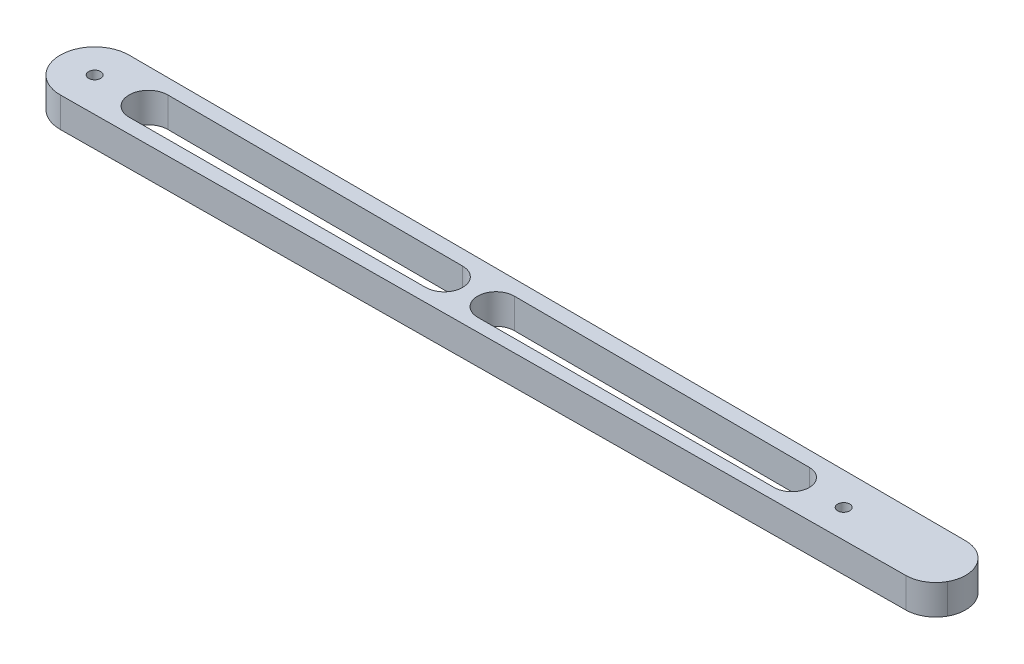
from build123d import *

# Parameters (mm, degrees)
SKETCH1_R           = 2
BOSS_EXTRUDE1_DEPTH = 10
CUT_EXTRUDE1_DEPTH  = 11


with BuildPart() as part:
    # Sketch1 → Boss-Extrude1 (new body)
    with BuildSketch(Plane(origin=(0, 0, 0), x_dir=(1, 0, 0), z_dir=(0, 1, 0))):
        with BuildLine():
            Line((0.090909042, -11.49964067), (280.070567987, -9.286294776))
            ThreePointArc((280.070567987, -9.286294776), (289.991484188, 0.738871766), (280.019610714, 10.7133533))
            Line((280.019610714, 10.7133533), (0.032308177, 11.499954617))
            ThreePointArc((0.032308177, 11.499954617), (-11.499962672, -0.029300853), (0.090909042, -11.49964067))
        make_face()
        with Locations((250, 0)):
            Circle(SKETCH1_R, mode=Mode.SUBTRACT)
        Circle(SKETCH1_R, mode=Mode.SUBTRACT)
    extrude(amount=BOSS_EXTRUDE1_DEPTH)

    # Sketch2 → Cut-Extrude1 (cut, through all)
    with BuildSketch(Plane(origin=(0, 10, 0), x_dir=(1, 0, 0), z_dir=(0, 1, 0))):
        with BuildLine():
            Line((17.967691823, 6.449546898), (116.670959066, 6.17224818))
            ThreePointArc((116.670959066, 6.17224818), (122.825891181, 0), (116.670959066, -6.17224818))
            Line((116.670959066, -6.17224818), (17.967691823, -6.449546898))
            ThreePointArc((17.967691823, -6.449546898), (11.5, 0), (17.967691823, 6.449546898))
        make_face()
        with BuildLine():
            Line((133.966776262, 6.123657003), (232.670043506, 5.846358285))
            ThreePointArc((232.670043506, 5.846358285), (238.5, 0), (232.670043506, -5.846358285))
            Line((232.670043506, -5.846358285), (133.966776262, -6.123657003))
            ThreePointArc((133.966776262, -6.123657003), (127.825891181, 0), (133.966776262, 6.123657003))
        make_face()
    extrude(amount=-CUT_EXTRUDE1_DEPTH, mode=Mode.SUBTRACT)


solid = part.part
